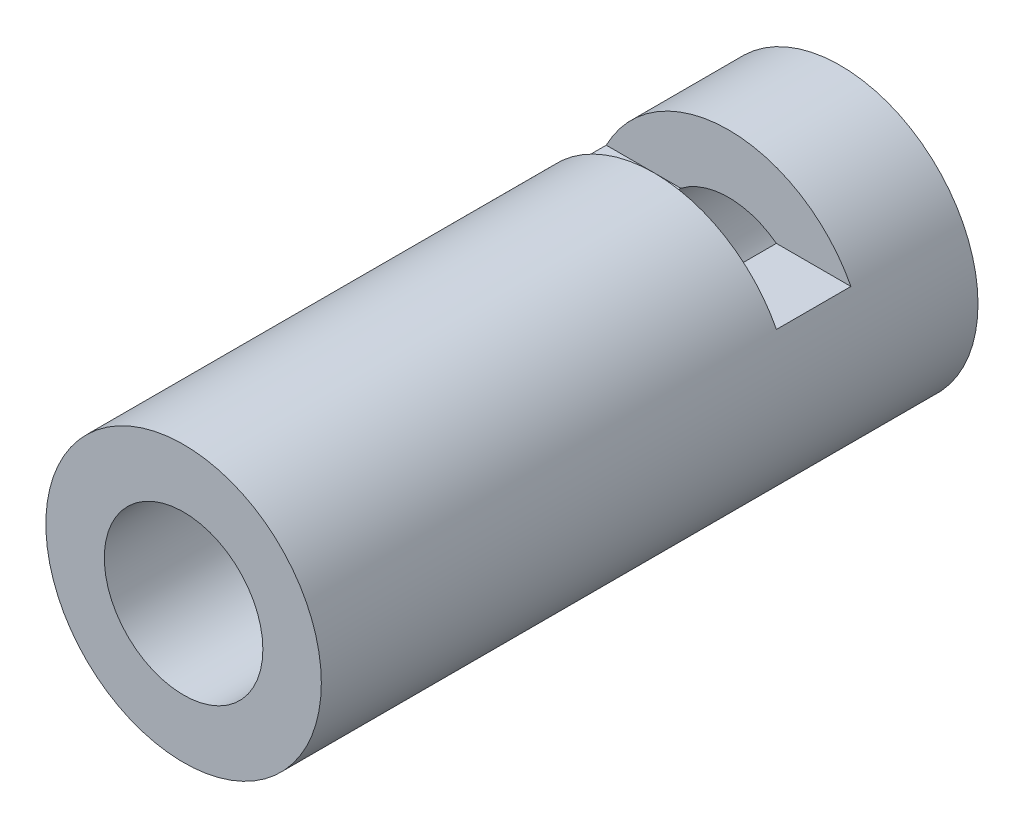
from build123d import *

# Parameters (mm, degrees)
SKIZZE1_R                            = 18.5
SKIZZE1_R_2                          = 10.65
AUFSATZ_LINEAR_AUSTRAGEN1_DEPTH      = 88.2
SKIZZE2_W                            = 10
SKIZZE2_H                            = 10
SCHNITT_LINEAR_AUSTRAGEN1_DEPTH      = 19.5
SCHNITT_LINEAR_AUSTRAGEN1_DEPTH_BACK = 19.5


with BuildPart() as part:
    # Skizze1 → Aufsatz-Linear austragen1 (new body)
    with BuildSketch(Plane.XY):
        Circle(SKIZZE1_R)
        Circle(SKIZZE1_R_2, mode=Mode.SUBTRACT)
    extrude(amount=AUFSATZ_LINEAR_AUSTRAGEN1_DEPTH)

    # Skizze2 → Schnitt-Linear austragen1 (cut, two sides)
    with BuildSketch(Plane(origin=(0, 0, 0), x_dir=(0, 0, -1), z_dir=(1, 0, 0))) as schnitt_linear_austragen1_sk:
        with Locations((-20, 13.5)):
            Rectangle(SKIZZE2_W, SKIZZE2_H)
    extrude(amount=SCHNITT_LINEAR_AUSTRAGEN1_DEPTH, mode=Mode.SUBTRACT)
    extrude(schnitt_linear_austragen1_sk.sketch, amount=-SCHNITT_LINEAR_AUSTRAGEN1_DEPTH_BACK, mode=Mode.SUBTRACT)


solid = part.part
